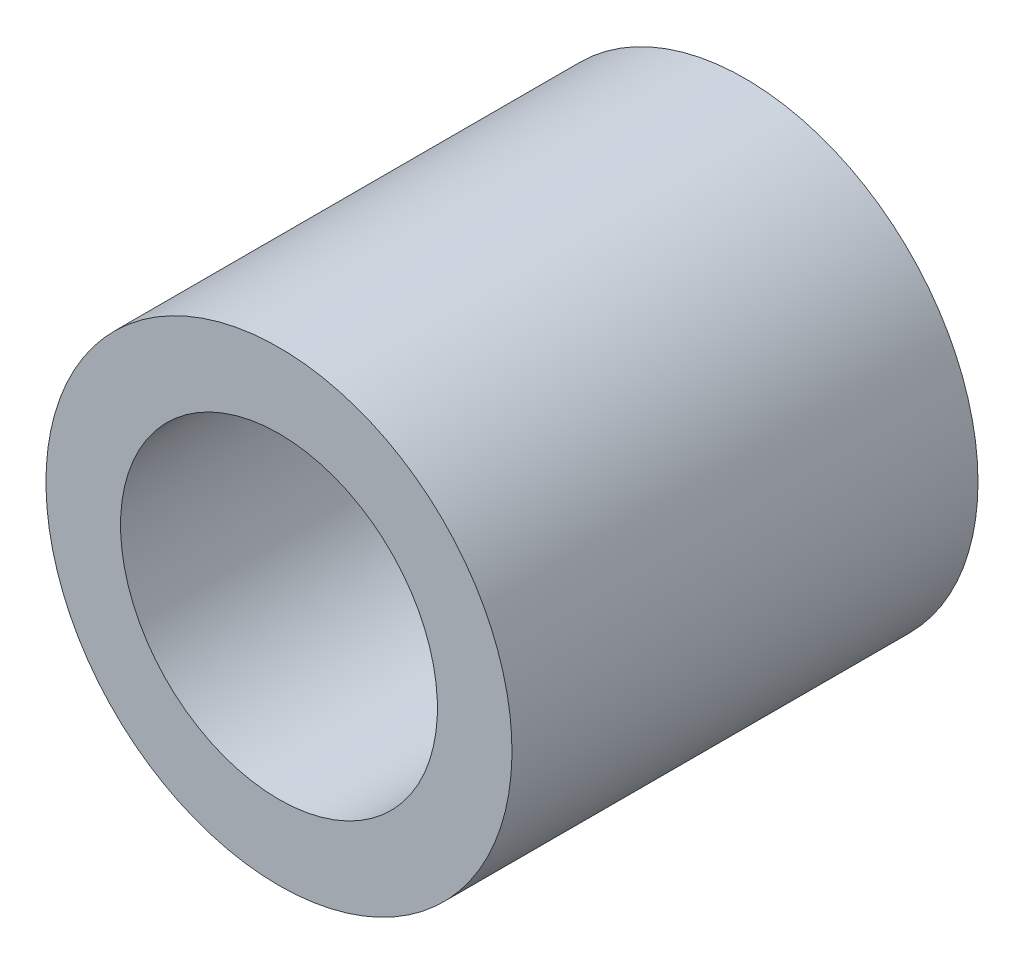
from build123d import *

# Parameters (mm, degrees)
ESQUISSE1_R        = 2.5
ESQUISSE1_R_2      = 1.7
BOSS_EXTRU_1_DEPTH = 5


with BuildPart() as part:
    # Esquisse1 → Boss.-Extru.1 (new body)
    with BuildSketch(Plane.XY):
        with Locations((-20.152592566, -28.52)):
            Circle(ESQUISSE1_R)
        with Locations((-20.152592566, -28.52)):
            Circle(ESQUISSE1_R_2, mode=Mode.SUBTRACT)
    extrude(amount=BOSS_EXTRU_1_DEPTH)


solid = part.part
